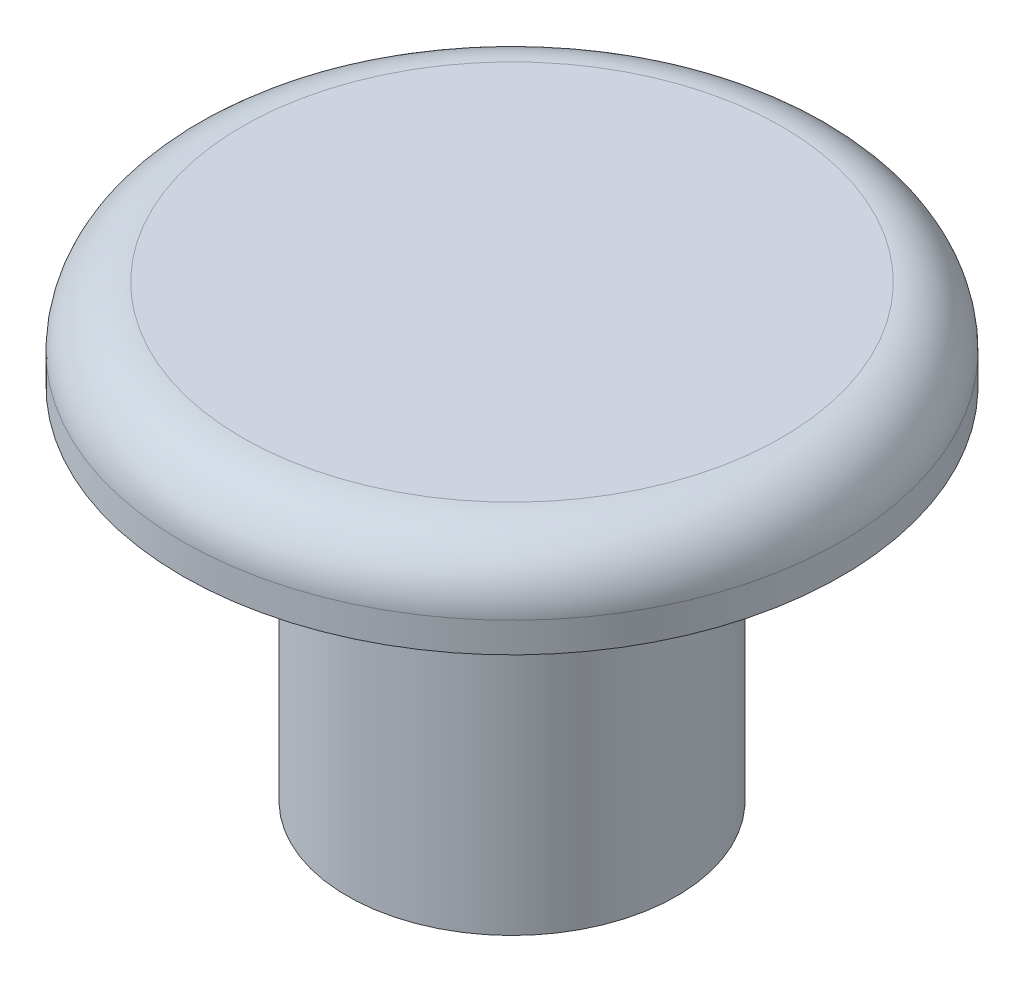
from build123d import *

# Parameters (mm, degrees)
FILLET1_R = 2


with BuildPart() as part:
    # Sketch1 → Revolve1 (revolve)
    with BuildSketch(Plane.XY):
        Polygon((0, 0), (5.5, 0), (5.5, 12), (11, 12), (11, 15), (0, 15), align=None)
    revolve(axis=Axis((0, 0, 0), (0, 1, 0)))

    # Fillet1
    fillet1_edges = [part.edges().sort_by_distance(p)[0] for p in [
        (-11, 15, 0),
    ]]
    fillet(fillet1_edges, radius=FILLET1_R)


solid = part.part
